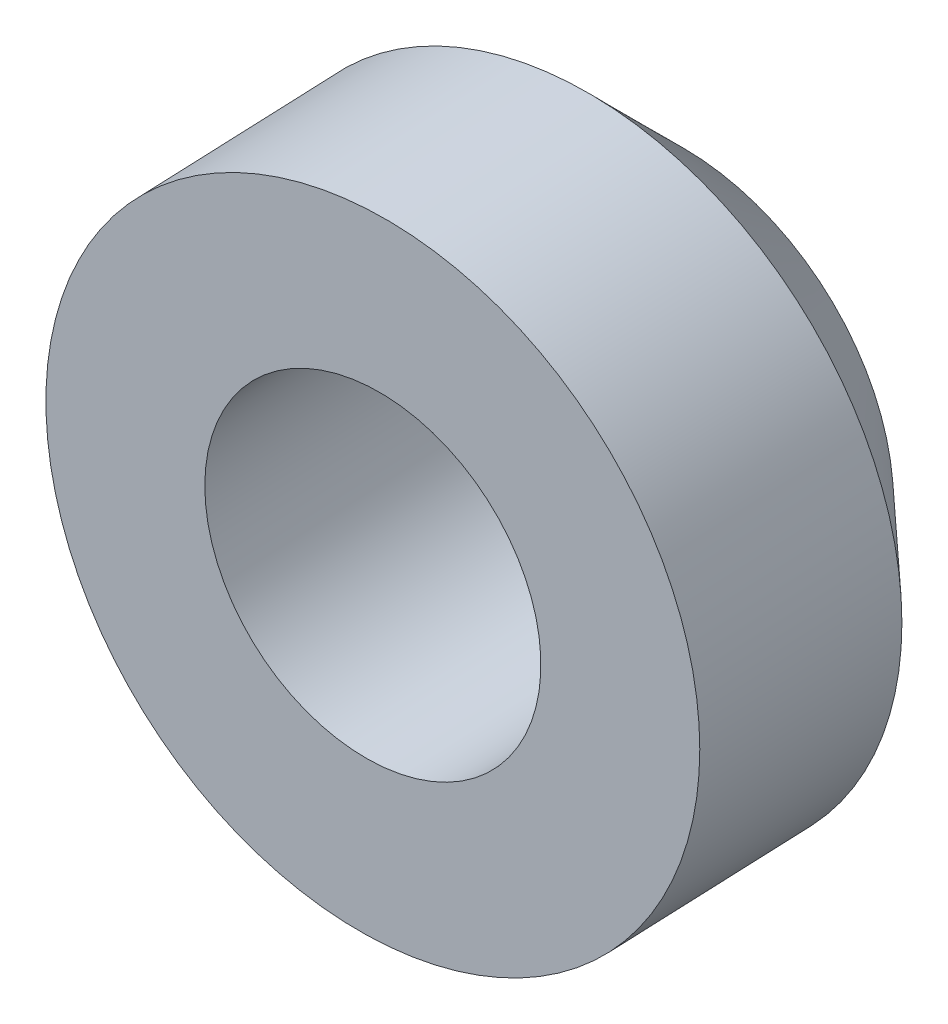
from build123d import *

# Parameters (mm, degrees)
F_1_4_CLEARANCE_HOLE1_D = 6.5278


with BuildPart() as part:
    # Sketch1 → Revolve1 (revolve)
    with BuildSketch(Plane(origin=(1571.632245604, 520.7, 291.338), x_dir=(-0.040181733, 0, -0.999192388), z_dir=(0.999192388, 0, -0.040181733))):
        Polygon((-6.858, -31.75), (-11.1125, -31.75), (-11.1125, -38.1), (-4.7625, -38.1), (-4.7625, -33.8455), align=None)
        Polygon((-11.1125, -31.75), (-11.1125, -38.1), (-4.7625, -38.1), (-4.7625, -33.8455), (-6.858, -31.75), align=None)
    revolve(axis=Axis((1572.07876511, 482.6, 302.441525412), (-0.040181733, 0, -0.999192388)))

    # 1/4 Clearance Hole1 (through all)
    with Locations(Plane(origin=(14.425889754, 0, 358.726173173), x_dir=(-0.999192388, 0, 0.040181733), z_dir=(-0.040181733, 0, -0.999192388))):
        with Locations((-1558.656510966, 482.6)):
            Hole(F_1_4_CLEARANCE_HOLE1_D / 2)


solid = part.part
